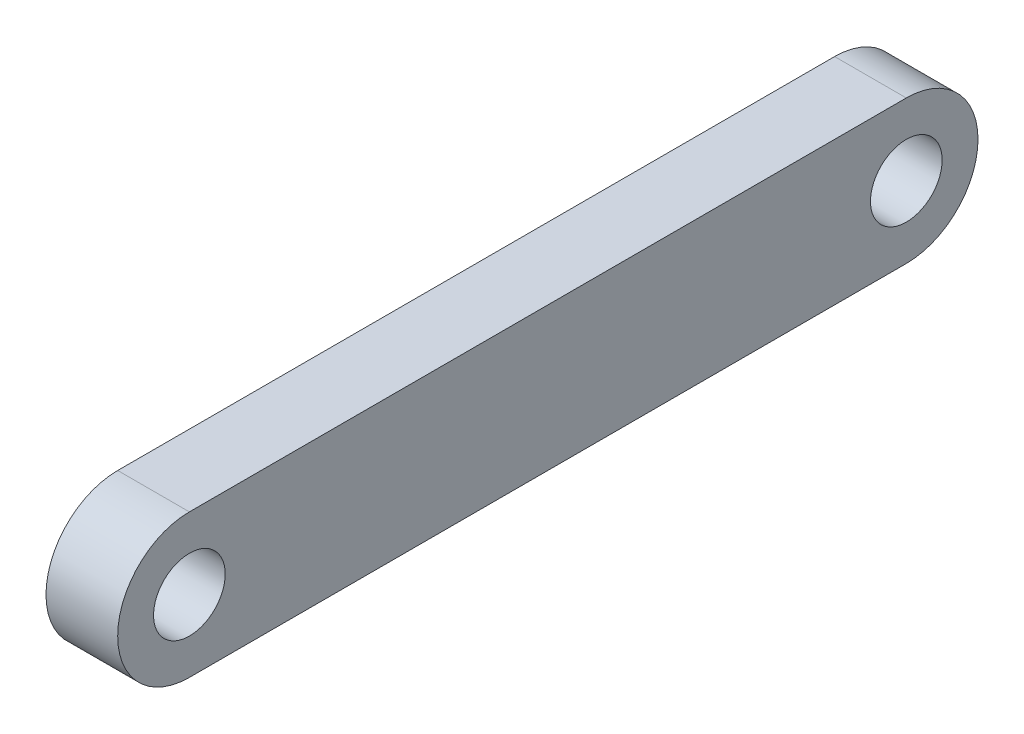
from build123d import *

# Parameters (mm, degrees)
SKETCH_1_R      = 4
EXTRUDE_1_DEPTH = 8


with BuildPart() as part:
    # 草图1 → 凸台-拉伸1 (new body)
    with BuildSketch(Plane(origin=(0, 0, 0), x_dir=(0, 0, -1), z_dir=(1, 0, 0))):
        with BuildLine():
            Line((0, 8), (80, 8))
            ThreePointArc((80, 8), (88, 0), (80, -8))
            Line((80, -8), (0, -8))
            ThreePointArc((0, -8), (-8, 0), (0, 8))
        make_face()
        Circle(SKETCH_1_R, mode=Mode.SUBTRACT)
        with Locations((80, 0)):
            Circle(SKETCH_1_R, mode=Mode.SUBTRACT)
    extrude(amount=EXTRUDE_1_DEPTH)


solid = part.part
